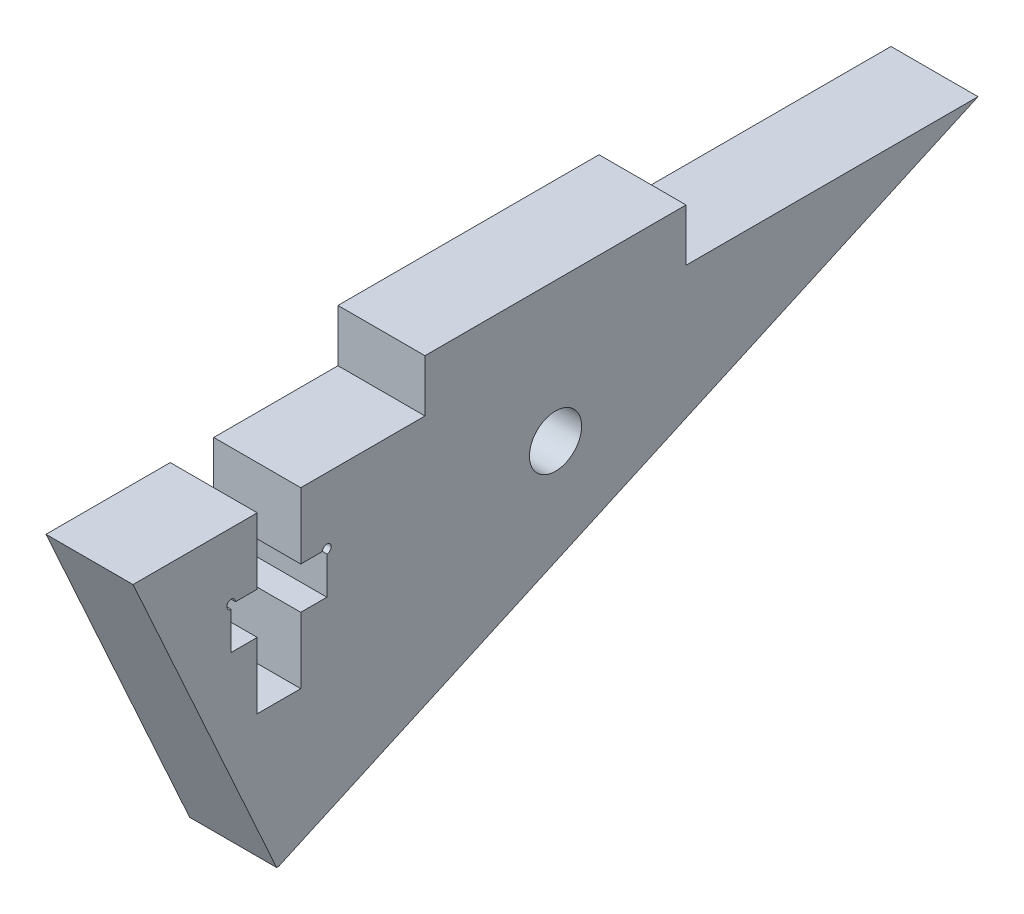
from build123d import *

# Parameters (mm, degrees)
SCHIZZO1_W                   = 48.55
SCHIZZO1_H                   = 18.21
ESTRUSIONE_ESTRUSIONE1_DEPTH = 5
TAGLIO_ESTRUSIONE1_DEPTH     = 6
SCHIZZO3_R                   = 1.5
TAGLIO_ESTRUSIONE2_DEPTH     = 6
SCHIZZO4_W                   = 5
SCHIZZO4_H                   = 15
ESTRUSIONE_ESTRUSIONE2_DEPTH = 3
TAGLIO_ESTRUSIONE3_DEPTH     = 6
SCHIZZO7_R                   = 0.25
TAGLIO_ESTRUSIONE4_DEPTH     = 6


with BuildPart() as part:
    # Schizzo1 → Estrusione-Estrusione1 (new body)
    with BuildSketch(Plane(origin=(0, 0, 0), x_dir=(0, 0, -1), z_dir=(1, 0, 0))):
        Rectangle(SCHIZZO1_W, SCHIZZO1_H)
    extrude(amount=ESTRUSIONE_ESTRUSIONE1_DEPTH)

    # Schizzo2 → Taglio-Estrusione1 (cut, through all)
    with BuildSketch(Plane(origin=(0, 0, 0), x_dir=(0, 0, -1), z_dir=(1, 0, 0))):
        Polygon((24.275, 9.105), (-15.905998409, -9.105), (24.275, -9.105), align=None)
        Polygon((-24.275, 9.105), (-24.275, -9.105), (-16.019269678, -9.111556119), align=None)
    extrude(amount=TAGLIO_ESTRUSIONE1_DEPTH, mode=Mode.SUBTRACT)

    # Schizzo3 → Taglio-Estrusione2 (cut, through all)
    with BuildSketch(Plane(origin=(0, 0, 0), x_dir=(0, 0, -1), z_dir=(1, 0, 0))):
        with Locations((0, 4.105)):
            Circle(SCHIZZO3_R)
    extrude(amount=TAGLIO_ESTRUSIONE2_DEPTH, mode=Mode.SUBTRACT)

    # Schizzo4 → Estrusione-Estrusione2 (add)
    with BuildSketch(Plane(origin=(0, 9.105, 0), x_dir=(1, 0, 0), z_dir=(0, 1, 0))):
        with Locations((2.5, 0)):
            Rectangle(SCHIZZO4_W, SCHIZZO4_H)
    extrude(amount=ESTRUSIONE_ESTRUSIONE2_DEPTH)

    # Schizzo6 → Taglio-Estrusione3 (cut, through all)
    with BuildSketch(Plane(origin=(0, 0, 0), x_dir=(0, 0, -1), z_dir=(1, 0, 0))):
        Polygon((-17.1375, -0.895), (-17.1375, 2.905), (-18.6375, 2.905), (-18.6375, 5.305), (-17.1375, 5.305), (-17.1375, 9.105), (-14.6375, 9.105), (-14.6375, 5.305), (-13.1375, 5.305), (-13.1375, 2.905), (-14.6375, 2.905), (-14.6375, -0.895), align=None)
    extrude(amount=TAGLIO_ESTRUSIONE3_DEPTH, mode=Mode.SUBTRACT)

    # Schizzo7 → Taglio-Estrusione4 (cut, through all)
    with BuildSketch(Plane(origin=(5, 0, 0), x_dir=(0, 0, -1), z_dir=(1, 0, 0))):
        with Locations((-18.6375, 5.305)):
            Circle(SCHIZZO7_R)
        with Locations((-13.1375, 5.305)):
            Circle(SCHIZZO7_R)
    extrude(amount=-TAGLIO_ESTRUSIONE4_DEPTH, mode=Mode.SUBTRACT)


solid = part.part
